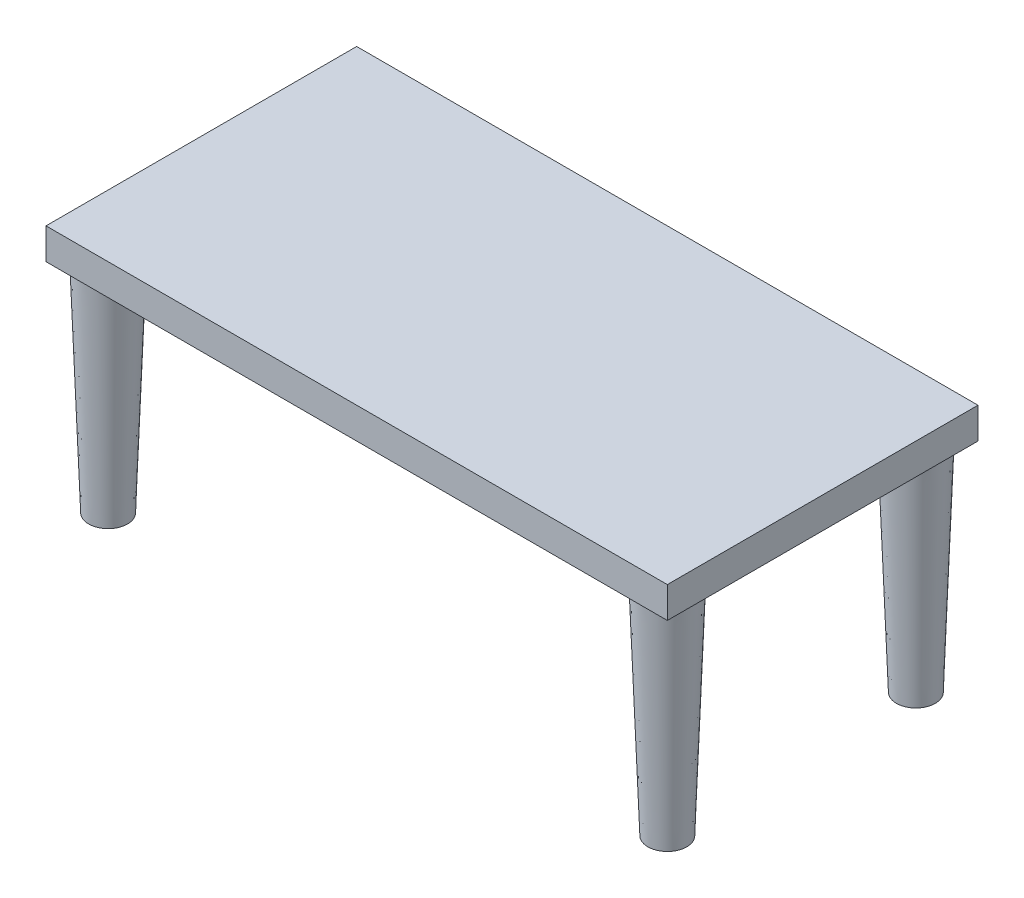
from build123d import *

# Parameters (mm, degrees)
SKETCH1_W           = 200
SKETCH1_H           = 100
BOSS_EXTRUDE1_DEPTH = 5
SKETCH2_R           = 8.75
SKETCH3_R           = 6.25
SKETCH2_4_R         = 8.75
SKETCH3_3_R         = 6.25
SKETCH2_5_R         = 8.75
SKETCH3_4_R         = 6.25
SKETCH2_6_R         = 8.75
SKETCH3_5_R         = 6.25


with BuildPart() as part:
    # Sketch1 → Boss-Extrude1 (new, symmetric)
    with BuildSketch(Plane(origin=(0, 0, 0), x_dir=(1, 0, 0), z_dir=(0, 1, 0))):
        Rectangle(SKETCH1_W, SKETCH1_H)
    extrude(amount=BOSS_EXTRUDE1_DEPTH, both=True)

    # Sketch2 → Loft1 section 0
    with BuildSketch(Plane.XZ.offset(5)):
        with Locations((-90, -40)):
            Circle(SKETCH2_R)
    # Sketch3 → Loft1 section 1
    with BuildSketch(Plane(origin=(0, -75, 0), x_dir=(1, 0, 0), z_dir=(0, 1, 0))):
        with Locations((-90, 40)):
            Circle(SKETCH3_R)
    loft()

    # Sketch2_4 → Loft2 section 0
    with BuildSketch(Plane.XZ.offset(5)):
        with Locations((-90, 40)):
            Circle(SKETCH2_4_R)
    # Sketch3_3 → Loft2 section 1
    with BuildSketch(Plane(origin=(0, -75, 0), x_dir=(1, 0, 0), z_dir=(0, 1, 0))):
        with Locations((-90, -40)):
            Circle(SKETCH3_3_R)
    loft()

    # Sketch2_5 → Loft3 section 0
    with BuildSketch(Plane.XZ.offset(5)):
        with Locations((90, 40)):
            Circle(SKETCH2_5_R)
    # Sketch3_4 → Loft3 section 1
    with BuildSketch(Plane(origin=(0, -75, 0), x_dir=(1, 0, 0), z_dir=(0, 1, 0))):
        with Locations((90, -40)):
            Circle(SKETCH3_4_R)
    loft()

    # Sketch2_6 → Loft4 section 0
    with BuildSketch(Plane.XZ.offset(5)):
        with Locations((90, -40)):
            Circle(SKETCH2_6_R)
    # Sketch3_5 → Loft4 section 1
    with BuildSketch(Plane(origin=(0, -75, 0), x_dir=(1, 0, 0), z_dir=(0, 1, 0))):
        with Locations((90, 40)):
            Circle(SKETCH3_5_R)
    loft()


solid = part.part
